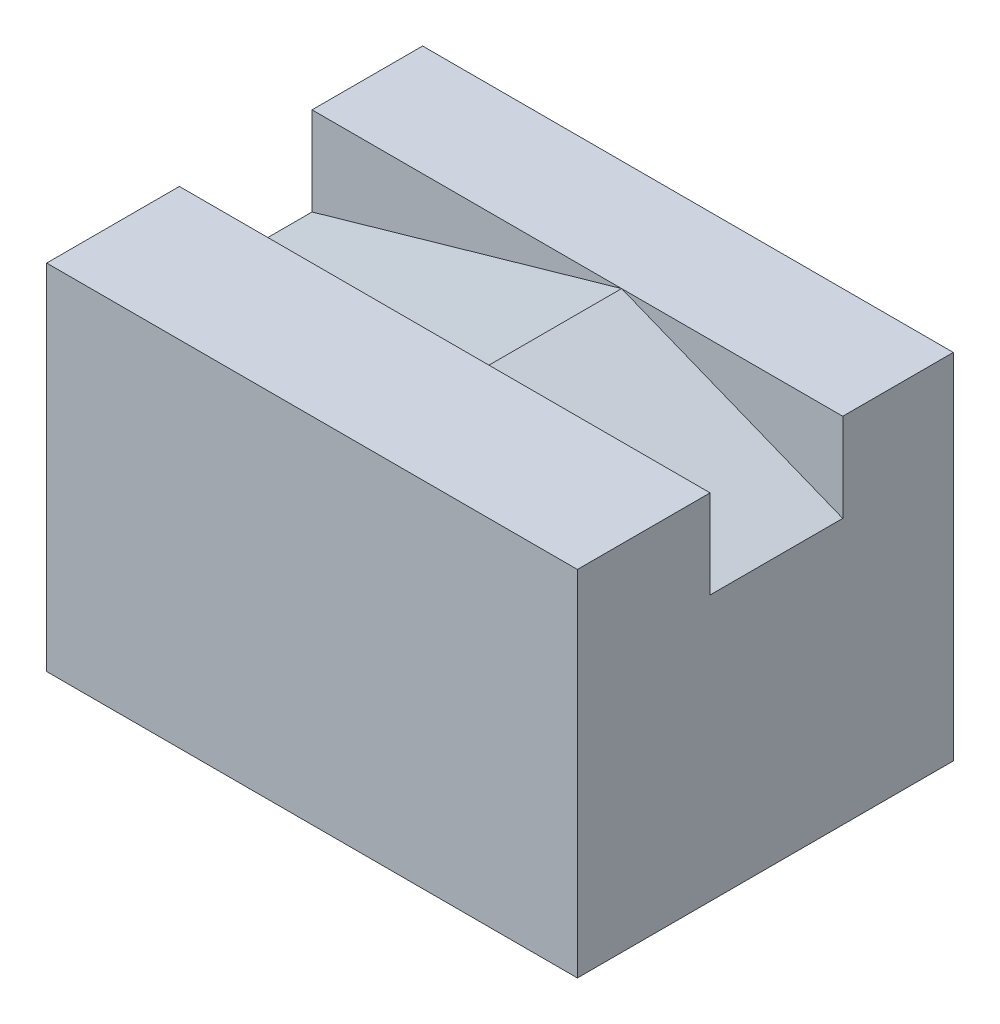
from build123d import *

# Parameters (mm, degrees)
SKETCH1_W           = 6
SKETCH1_H           = 4
BOSS_EXTRUDE1_DEPTH = 1.25
BOSS_EXTRUDE2_DEPTH = 1.5
BOSS_EXTRUDE3_START = 1.5
BOSS_EXTRUDE3_DEPTH = 1.5


with BuildPart() as part:
    # Sketch1 → Boss-Extrude1 (new body)
    with BuildSketch(Plane.XY):
        Rectangle(SKETCH1_W, SKETCH1_H)
    extrude(amount=-BOSS_EXTRUDE1_DEPTH)

    # Sketch1_3 → Boss-Extrude2 (add)
    with BuildSketch(Plane.XY):
        Polygon((0.5, 2), (-3, 1), (-3, -2), (3, -2), (3, 1), align=None)
    extrude(amount=BOSS_EXTRUDE2_DEPTH)

    # Sketch1_4 → Boss-Extrude3 (add)
    with BuildSketch(Plane.XY.offset(BOSS_EXTRUDE3_START)):
        Polygon((-3, 2), (-3, 1), (0.5, 2), align=None)
        Polygon((0.5, 2), (-3, 1), (-3, -2), (3, -2), (3, 1), align=None)
        Polygon((3, 2), (0.5, 2), (3, 1), align=None)
    extrude(amount=BOSS_EXTRUDE3_DEPTH)


solid = part.part
